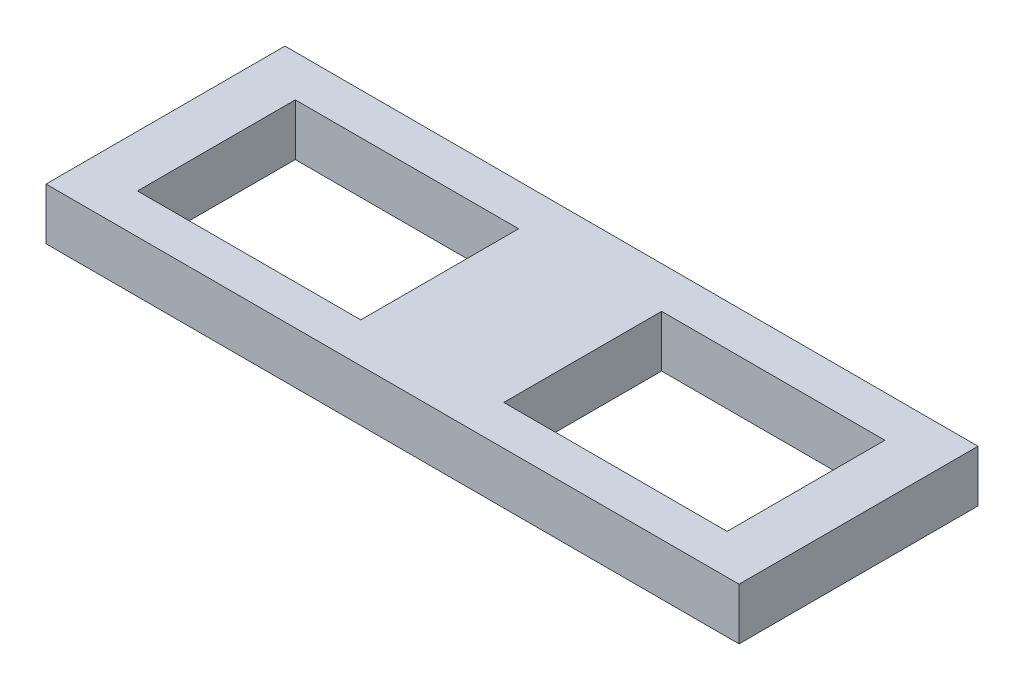
from build123d import *

# Parameters (mm, degrees)
CROQUIS1_W              = 134
CROQUIS1_H              = 46.2
CROQUIS1_W_2            = 43.177671481
CROQUIS1_H_2            = 30.51386392
SALIENTE_EXTRUIR2_DEPTH = 10


with BuildPart() as part:
    # Croquis1 → Saliente-Extruir2 (new body)
    with BuildSketch(Plane(origin=(0, 0, 0), x_dir=(1, 0, 0), z_dir=(0, 1, 0))):
        with Locations((67, 23.1)):
            Rectangle(CROQUIS1_W, CROQUIS1_H)
        with Locations((31.588835741, 22.94306804)):
            Rectangle(CROQUIS1_W_2, CROQUIS1_H_2, mode=Mode.SUBTRACT)
        with Locations((102.41116426, 22.94306804)):
            Rectangle(CROQUIS1_W_2, CROQUIS1_H_2, mode=Mode.SUBTRACT)
    extrude(amount=SALIENTE_EXTRUIR2_DEPTH)


solid = part.part
